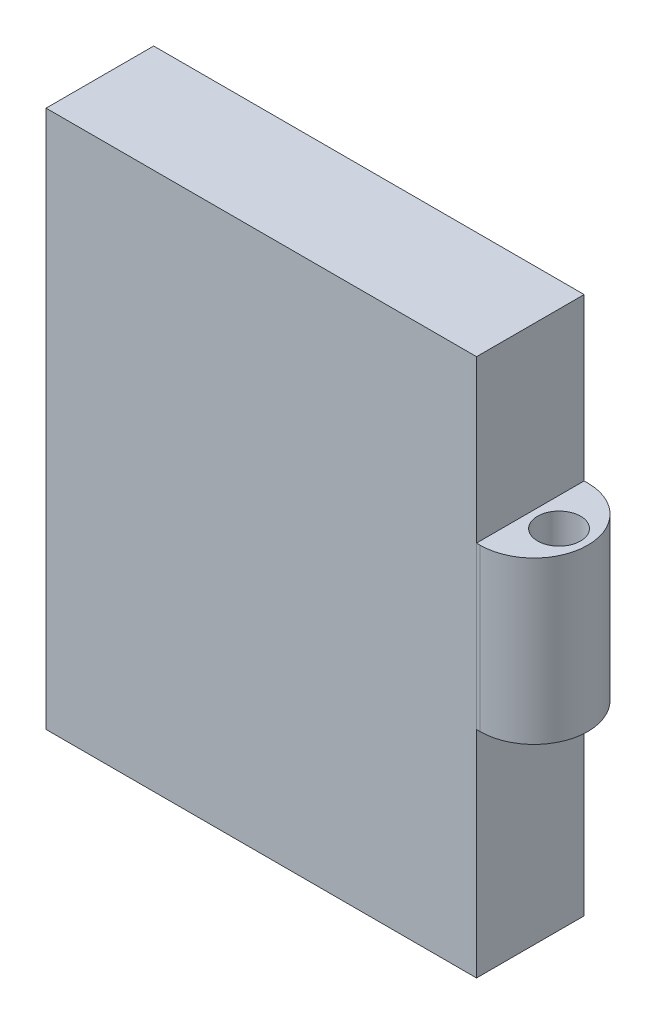
from build123d import *

# Parameters (mm, degrees)
SKETCH1_W           = 40
SKETCH1_H           = 50
BOSS_EXTRUDE1_DEPTH = 10
SHELL4_T            = 3
BOSS_EXTRUDE4_START = -15
SKETCH4_R           = 2
BOSS_EXTRUDE4_DEPTH = 15
SKETCH9_R           = 0.5
CUT_EXTRUDE2_DEPTH  = 5


with BuildPart() as part:
    # Sketch1 → Boss-Extrude1 (new body)
    with BuildSketch(Plane.XY):
        with Locations((20, 25)):
            Rectangle(SKETCH1_W, SKETCH1_H)
    extrude(amount=BOSS_EXTRUDE1_DEPTH)

    # Shell4 (no face opened: a closed hollow body)
    add(offset(amount=-SHELL4_T, mode=Mode.PRIVATE), mode=Mode.SUBTRACT)

    # Sketch4 → Boss-Extrude4 (add)
    with BuildSketch(Plane(origin=(0, 50, 0), x_dir=(1, 0, 0), z_dir=(0, 1, 0)).offset(BOSS_EXTRUDE4_START)):
        with BuildLine():
            Line((40, 0), (40.33712564, 0))
            ThreePointArc((40.33712564, 0), (45.339222659, -5.002097019), (40.33712564, -10.004194037))
            Line((40.33712564, -10.004194037), (40, -10))
            Line((40, -10), (40, 0))
        make_face()
        with Locations((42.669611329, -5.001048509)):
            Circle(SKETCH4_R, mode=Mode.SUBTRACT)
    extrude(amount=-BOSS_EXTRUDE4_DEPTH)

    # Sketch9 → Cut-Extrude2 (cut)
    with BuildSketch(Plane(origin=(0, 0, 0), x_dir=(-1, 0, 0), z_dir=(0, 0, -1))):
        with Locations((-38, 15)):
            Circle(SKETCH9_R)
        with Locations((-35, 15)):
            Circle(SKETCH9_R)
        with Locations((-32, 15)):
            Circle(SKETCH9_R)
        with Locations((-29, 15)):
            Circle(SKETCH9_R)
        with Locations((-26, 15)):
            Circle(SKETCH9_R)
        with Locations((-35, 12)):
            Circle(SKETCH9_R)
        with Locations((-32, 12)):
            Circle(SKETCH9_R)
        with Locations((-29, 12)):
            Circle(SKETCH9_R)
        with Locations((-26, 12)):
            Circle(SKETCH9_R)
        with Locations((-35, 9)):
            Circle(SKETCH9_R)
        with Locations((-32, 9)):
            Circle(SKETCH9_R)
        with Locations((-29, 9)):
            Circle(SKETCH9_R)
        with Locations((-26, 9)):
            Circle(SKETCH9_R)
        with Locations((-35, 6)):
            Circle(SKETCH9_R)
        with Locations((-32, 6)):
            Circle(SKETCH9_R)
        with Locations((-29, 6)):
            Circle(SKETCH9_R)
        with Locations((-26, 6)):
            Circle(SKETCH9_R)
        with Locations((-35, 3)):
            Circle(SKETCH9_R)
        with Locations((-32, 3)):
            Circle(SKETCH9_R)
        with Locations((-29, 3)):
            Circle(SKETCH9_R)
        with Locations((-26, 3)):
            Circle(SKETCH9_R)
        with Locations((-38, 12)):
            Circle(SKETCH9_R)
        with Locations((-38, 9)):
            Circle(SKETCH9_R)
        with Locations((-38, 6)):
            Circle(SKETCH9_R)
        with Locations((-38, 3)):
            Circle(SKETCH9_R)
    extrude(amount=-CUT_EXTRUDE2_DEPTH, mode=Mode.SUBTRACT)


solid = part.part
